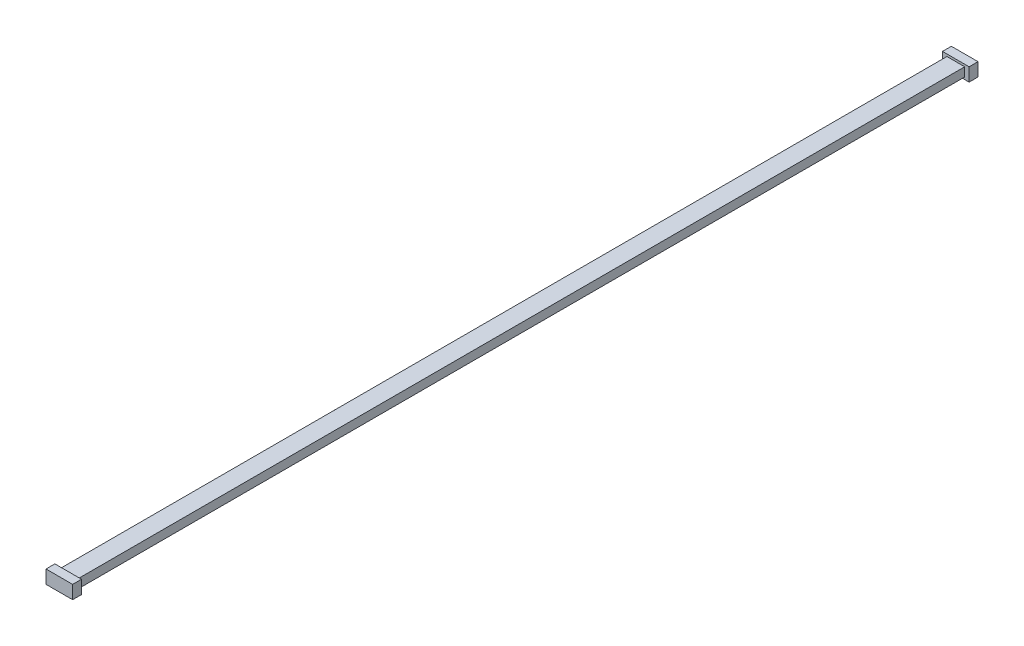
from build123d import *

# Parameters (mm, degrees)
ESQUISSE1_W        = 20
ESQUISSE1_H        = 10
BOSS_EXTRU_1_DEPTH = 500
ESQUISSE2_W        = 30
ESQUISSE2_H        = 15
BOSS_EXTRU_2_DEPTH = 10


with BuildPart() as part:
    # Esquisse1 → Boss.-Extru.1 (new body)
    with BuildSketch(Plane.XY):
        Rectangle(ESQUISSE1_W, ESQUISSE1_H)
    boss_extru_1 = extrude(amount=BOSS_EXTRU_1_DEPTH)

    # Esquisse2 → Boss.-Extru.2 (add)
    with BuildSketch(Plane.XY.offset(500)):
        Rectangle(ESQUISSE2_W, ESQUISSE2_H)
    boss_extru_2 = extrude(amount=BOSS_EXTRU_2_DEPTH)

    # Symétrie1: Boss.-Extru.1, Boss.-Extru.2 across plane
    add(boss_extru_1.mirror(Plane.XY))
    add(boss_extru_2.mirror(Plane.XY))


solid = part.part
